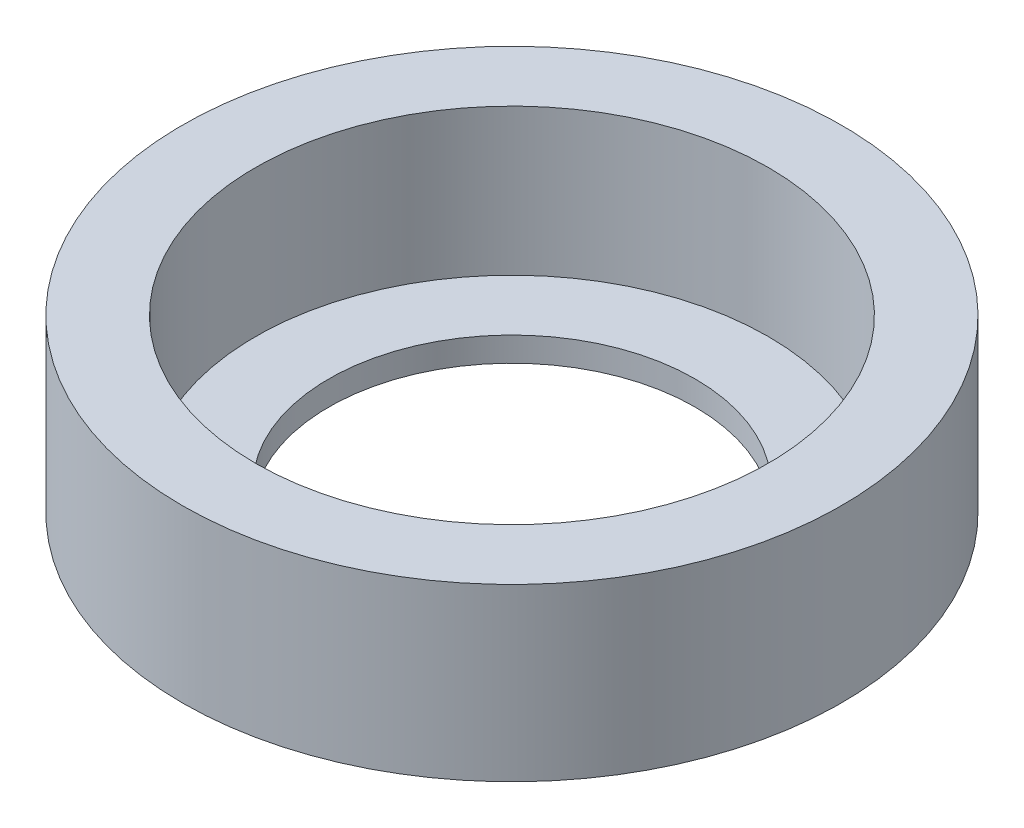
from build123d import *

# Parameters (mm, degrees)
SCHIZZO1_R                   = 13.5
SCHIZZO1_R_2                 = 7.5
ESTRUSIONE_ESTRUSIONE1_DEPTH = 7
SCHIZZO2_R                   = 10.5
TAGLIO_ESTRUSIONE1_DEPTH     = 6


with BuildPart() as part:
    # Schizzo1 → Estrusione-Estrusione1 (new body)
    with BuildSketch(Plane(origin=(0, 0, 0), x_dir=(1, 0, 0), z_dir=(0, 1, 0))):
        Circle(SCHIZZO1_R)
        Circle(SCHIZZO1_R_2, mode=Mode.SUBTRACT)
    extrude(amount=ESTRUSIONE_ESTRUSIONE1_DEPTH)

    # Schizzo2 → Taglio-Estrusione1 (cut)
    with BuildSketch(Plane(origin=(0, 7, 0), x_dir=(1, 0, 0), z_dir=(0, 1, 0))):
        Circle(SCHIZZO2_R)
    extrude(amount=-TAGLIO_ESTRUSIONE1_DEPTH, mode=Mode.SUBTRACT)


solid = part.part
